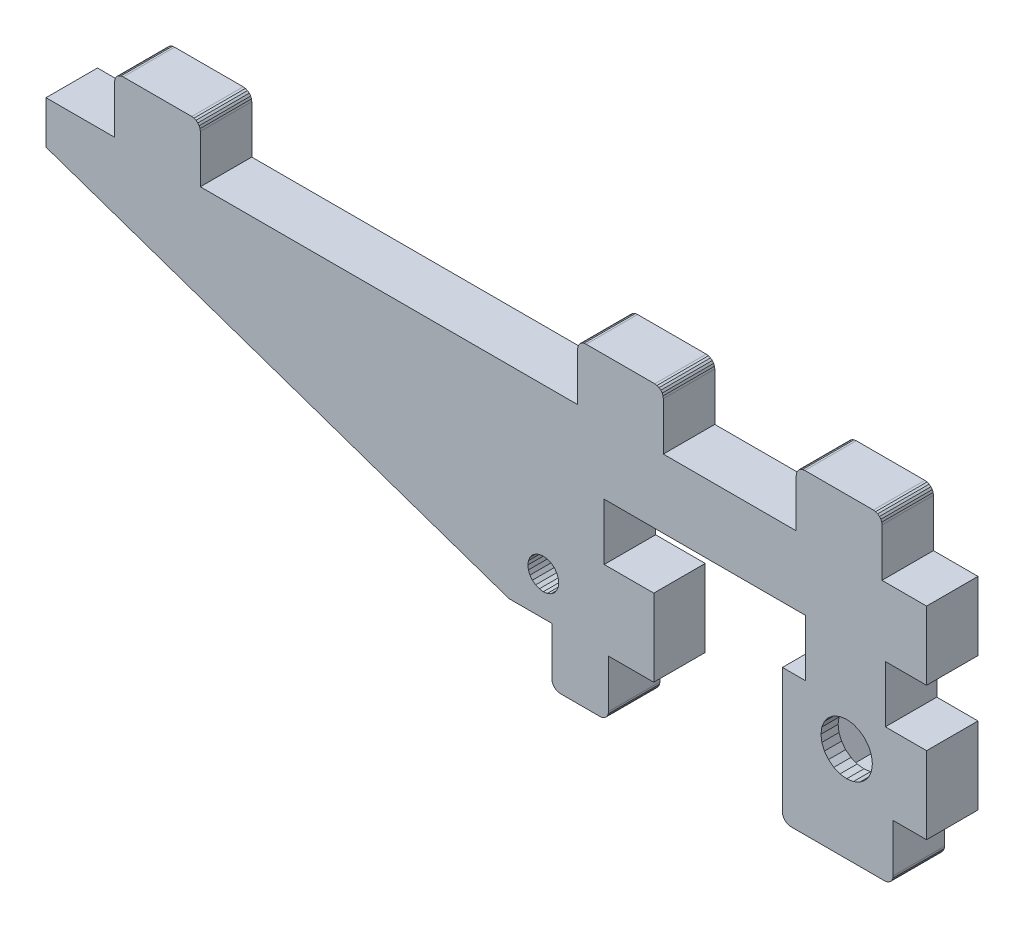
from build123d import *

# Parameters (mm, degrees)
BOSS_EXTRUDE1_DEPTH = 6
BOSS_EXTRUDE2_DEPTH = 2


with BuildPart() as part:
    # Sketch1 → Boss-Extrude1 (new body)
    with BuildSketch(Plane.XY):
        Polygon((-501.164421084, -368.48209059), (-501.198495258, -368.740909635), (-501.198495258, -374.340909635), (-509.198495258, -374.340909635), (-509.198495258, -379.340909635), (-455.198495258, -397.940909635), (-450.198495258, -397.940909635), (-450.198495258, -403.540909635), (-450.164421084, -403.79972868), (-450.064520662, -404.040909635), (-449.905602039, -404.248016416), (-449.698495258, -404.406935039), (-449.457314303, -404.506835462), (-449.198495258, -404.540909635), (-444.598495258, -404.540909635), (-444.339676213, -404.506835462), (-444.098495258, -404.406935039), (-443.891388477, -404.248016416), (-443.732469854, -404.040909635), (-443.632569432, -403.79972868), (-443.598495258, -403.540909635), (-443.598495258, -397.940909635), (-438.315958847, -397.940909635), (-438.315958847, -388.940909635), (-444.098495258, -388.940909635), (-444.098495258, -382.340909635), (-420.598495258, -382.340909635), (-420.598495258, -388.940909635), (-423.310770682, -388.940909635), (-423.310770682, -403.540909635), (-423.276696508, -403.79972868), (-423.176796086, -404.040909635), (-423.017877463, -404.248016416), (-422.810770682, -404.406935039), (-422.569589727, -404.506835462), (-422.310770682, -404.540909635), (-411.398495258, -404.540909635), (-411.139676213, -404.506835462), (-410.898495258, -404.406935039), (-410.691388477, -404.248016416), (-410.532469854, -404.040909635), (-410.432569432, -403.79972868), (-410.398495258, -403.540909635), (-410.398495258, -397.940909635), (-406.500225377, -397.940909635), (-406.500225377, -388.94468827), (-411.303687136, -388.940909635), (-411.298495258, -382.340909635), (-406.500225377, -382.344686145), (-406.500225377, -374.340909635), (-411.698495258, -374.340909635), (-411.698495258, -368.740909635), (-411.732569432, -368.48209059), (-411.832469854, -368.240909635), (-411.991388477, -368.033802854), (-412.198495258, -367.874884232), (-412.439676213, -367.774983809), (-412.698495258, -367.740909635), (-420.698495258, -367.740909635), (-420.957314303, -367.774983809), (-421.198495258, -367.874884232), (-421.405602039, -368.033802854), (-421.564520662, -368.240909635), (-421.664421084, -368.48209059), (-421.698495258, -368.740909635), (-421.698495258, -374.340909635), (-437.198495258, -374.340909635), (-437.198495258, -368.740909635), (-437.232569432, -368.48209059), (-437.332469854, -368.240909635), (-437.491388477, -368.033802854), (-437.698495258, -367.874884232), (-437.939676213, -367.774983809), (-438.198495258, -367.740909635), (-446.198495258, -367.740909635), (-446.457314303, -367.774983809), (-446.698495258, -367.874884232), (-446.905602039, -368.033802854), (-447.064520662, -368.240909635), (-447.164421084, -368.48209059), (-447.198495258, -368.740909635), (-447.198495258, -374.340909635), (-491.198495258, -374.340909635), (-491.198495258, -368.740909635), (-491.232569432, -368.48209059), (-491.332469854, -368.240909635), (-491.491388477, -368.033802854), (-491.698495258, -367.874884232), (-491.939676213, -367.774983809), (-492.198495258, -367.740909635), (-500.198495258, -367.740909635), (-500.457314303, -367.774983809), (-500.698495258, -367.874884232), (-500.905602039, -368.033802854), (-501.064520662, -368.240909635), align=None)
        Polygon((-451.664369539, -391.702243148), (-451.198495258, -391.640909635), (-450.732620977, -391.702243148), (-450.298495258, -391.882063909), (-449.925703052, -392.168117429), (-449.639649531, -392.540909635), (-449.459828771, -392.975035354), (-449.398495258, -393.440909635), (-449.459828771, -393.906783916), (-449.639649531, -394.340909635), (-449.925703052, -394.713701841), (-450.298495258, -394.999755362), (-450.732620977, -395.179576123), (-451.198495258, -395.240909635), (-451.664369539, -395.179576123), (-452.098495258, -394.999755362), (-452.471287464, -394.713701841), (-452.757340985, -394.340909635), (-452.937161745, -393.906783916), (-452.998495258, -393.440909635), (-452.937161745, -392.975035354), (-452.757340985, -392.540909635), (-452.471287464, -392.168117429), (-452.098495258, -391.882063909), align=None, mode=Mode.SUBTRACT)
        Polygon((-418.414035058, -388.940909635), (-413.217882636, -388.940909635), (-410.619806424, -393.440909635), (-413.217882636, -397.940909635), (-418.414035058, -397.940909635), (-421.01211127, -393.440909635), align=None, mode=Mode.SUBTRACT)
    extrude(amount=-BOSS_EXTRUDE1_DEPTH)

    # Sketch1_3 → Boss-Extrude2 (add)
    with BuildSketch(Plane.XY):
        Polygon((-410.619806424, -393.440909635), (-413.217882636, -388.940909635), (-418.414035058, -388.940909635), (-421.01211127, -393.440909635), (-418.414035058, -397.940909635), (-413.217882636, -397.940909635), align=None)
        Polygon((-415.039501712, -390.543132156), (-414.315958847, -390.842833424), (-413.694638503, -391.319589292), (-413.217882636, -391.940909635), (-412.918181368, -392.6644525), (-412.815958847, -393.440909635), (-412.918181368, -394.217366771), (-413.217882636, -394.940909635), (-413.694638503, -395.562229979), (-414.315958847, -396.038985847), (-415.039501712, -396.338687114), (-415.815958847, -396.440909635), (-416.592415982, -396.338687114), (-417.315958847, -396.038985847), (-417.937279191, -395.562229979), (-418.414035058, -394.940909635), (-418.713736326, -394.217366771), (-418.815958847, -393.440909635), (-418.713736326, -392.6644525), (-418.414035058, -391.940909635), (-417.937279191, -391.319589292), (-417.315958847, -390.842833424), (-416.592415982, -390.543132156), (-415.815958847, -390.440909635), align=None, mode=Mode.SUBTRACT)
    extrude(amount=-BOSS_EXTRUDE2_DEPTH)


solid = part.part
